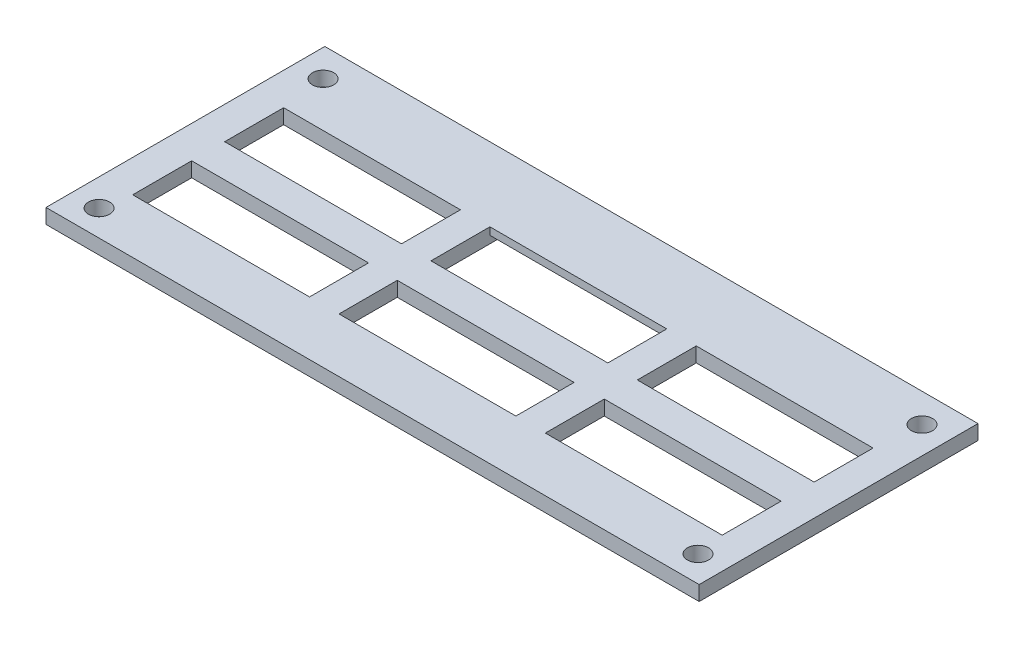
from build123d import *

# Parameters (mm, degrees)
SKETCH3_W           = 140.715997696
SKETCH3_H           = 60.070999146
SKETCH3_R           = 2.286
SKETCH3_W_2         = 38.1
SKETCH3_H_2         = 12.7
SKETCH3_H_3         = 12.548758089
SKETCH3_H_4         = 22.298299906
BOSS_EXTRUDE1_DEPTH = 3.175
SKETCH4_W           = 38.1
SKETCH4_H           = 9.598299906
BOSS_EXTRUDE2_DEPTH = 1.5875


with BuildPart() as part:
    # Sketch3 → Boss-Extrude1 (new body)
    with BuildSketch(Plane(origin=(0, 0, 0), x_dir=(1, 0, 0), z_dir=(0, 1, 0))):
        with Locations((0.695262938, 7.925997488)):
            Rectangle(SKETCH3_W, SKETCH3_H)
        with Locations((65.211264471, -16.521503733)):
            Circle(SKETCH3_R, mode=Mode.SUBTRACT)
        with Locations((45.270791396, -4.068621014)):
            Rectangle(SKETCH3_W_2, SKETCH3_H_2, mode=Mode.SUBTRACT)
        with Locations((45.270791396, 15.743378986)):
            Rectangle(SKETCH3_W_2, SKETCH3_H_2, mode=Mode.SUBTRACT)
        with Locations((0.820791396, -4.14424197)):
            Rectangle(SKETCH3_W_2, SKETCH3_H_3, mode=Mode.SUBTRACT)
        with Locations((0.820791396, 20.542528939)):
            Rectangle(SKETCH3_W_2, SKETCH3_H_4, mode=Mode.SUBTRACT)
        with Locations((-63.820735529, -16.521503733)):
            Circle(SKETCH3_R, mode=Mode.SUBTRACT)
        with Locations((-43.629208604, -4.068621014)):
            Rectangle(SKETCH3_W_2, SKETCH3_H_2, mode=Mode.SUBTRACT)
        with Locations((-43.629208604, 15.743378986)):
            Rectangle(SKETCH3_W_2, SKETCH3_H_2, mode=Mode.SUBTRACT)
        with Locations((-63.820735529, 31.738496267)):
            Circle(SKETCH3_R, mode=Mode.SUBTRACT)
        with Locations((65.211264471, 31.738496267)):
            Circle(SKETCH3_R, mode=Mode.SUBTRACT)
    extrude(amount=BOSS_EXTRUDE1_DEPTH)

    # Sketch4 → Boss-Extrude2 (add)
    with BuildSketch(Plane(origin=(0, 3.175, 0), x_dir=(1, 0, 0), z_dir=(0, 1, 0))):
        with Locations((0.820791396, 26.892528939)):
            Rectangle(SKETCH4_W, SKETCH4_H)
    extrude(amount=-BOSS_EXTRUDE2_DEPTH)


solid = part.part
